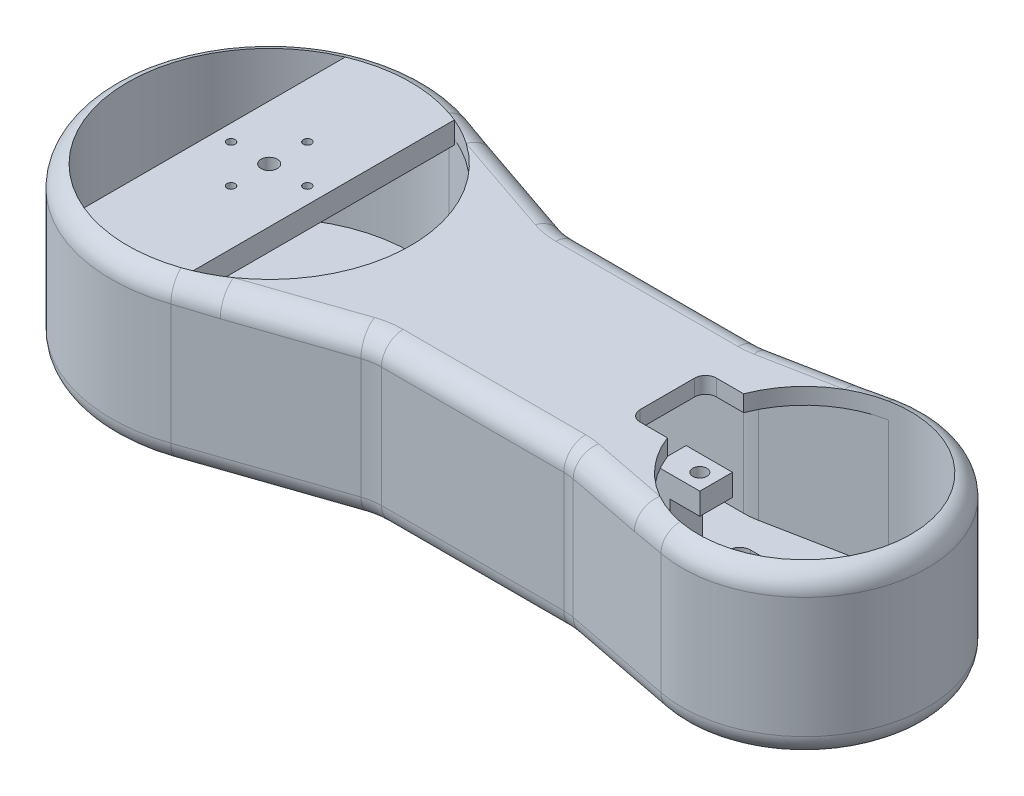
from build123d import *

# Parameters (mm, degrees)
BOSS_EXTRUDE1_DEPTH = 30
CUT_EXTRUDE3_START  = -3
CUT_EXTRUDE3_DEPTH  = 24
SKETCH6_R           = 25.98
SKETCH6_R_2         = 19.5
CUT_EXTRUDE4_DEPTH  = 9
FILLET1_R           = 4
SKETCH7_R           = 0.75
SKETCH7_R_2         = 1.5
BOSS_EXTRUDE2_DEPTH = 4
SKETCH8_R           = 5
CUT_EXTRUDE5_DEPTH  = 4
BOSS_EXTRUDE3_DEPTH = 4
SKETCH11_W          = 5.5
SKETCH11_H          = 6
SKETCH11_R          = 1.3
BOSS_EXTRUDE4_DEPTH = 4
SKETCH13_W          = 3
SKETCH13_H          = 6
BOSS_EXTRUDE5_DEPTH = 17.5
CUT_EXTRUDE6_DEPTH  = 4
CUT_EXTRUDE10_DEPTH = 4


with BuildPart() as part:
    # Sketch1 → Boss-Extrude1 (new body)
    with BuildSketch(Plane(origin=(0, 0, 0), x_dir=(1, 0, 0), z_dir=(0, 1, 0))):
        with BuildLine():
            Line((9.371736046, 27.4228183), (35.371736046, 18.537329779))
            ThreePointArc((35.371736046, 18.537329779), (36.966499389, 18.135247033), (38.605599416, 18))
            Line((38.605599416, 18), (72.067981377, 18))
            ThreePointArc((72.067981377, 18), (73.029258276, 18.046309894), (73.981631849, 18.184810655))
            Line((73.981631849, 18.184810655), (93.981631849, 22.084176026))
            ThreePointArc((93.981631849, 22.084176026), (120.78734541, 0), (93.981631849, -22.084176026))
            Line((93.981631849, -22.084176026), (73.981631849, -18.184810655))
            ThreePointArc((73.981631849, -18.184810655), (73.029258276, -18.046309894), (72.067981377, -18))
            Line((72.067981377, -18), (38.605599416, -18))
            ThreePointArc((38.605599416, -18), (36.966499389, -18.135247033), (35.371736046, -18.537329779))
            Line((35.371736046, -18.537329779), (9.371736046, -27.4228183))
            ThreePointArc((9.371736046, -27.4228183), (-28.98, 0), (9.371736046, 27.4228183))
        make_face()
    extrude(amount=BOSS_EXTRUDE1_DEPTH)

    # Sketch5 → Cut-Extrude3 (cut)
    with BuildSketch(Plane(origin=(0, 30, 0), x_dir=(1, 0, 0), z_dir=(0, 1, 0)).offset(CUT_EXTRUDE3_START)):
        with BuildLine():
            Line((8.401577035, -24.584017233), (34.401577035, -15.698528713))
            ThreePointArc((34.401577035, -15.698528713), (36.474769381, -15.175821143), (38.605599416, -15))
            Line((38.605599416, -15), (72.067981377, -15))
            ThreePointArc((72.067981377, -15), (73.317641346, -15.060202862), (74.55572699, -15.240253852))
            Line((74.55572699, -15.240253852), (94.55572699, -19.139619222))
            ThreePointArc((94.55572699, -19.139619222), (117.78734541, 0), (94.55572699, 19.139619222))
            Line((94.55572699, 19.139619222), (74.55572699, 15.240253852))
            ThreePointArc((74.55572699, 15.240253852), (73.317641346, 15.060202862), (72.067981377, 15))
            Line((72.067981377, 15), (38.605599416, 15))
            ThreePointArc((38.605599416, 15), (36.474769381, 15.175821143), (34.401577035, 15.698528713))
            Line((34.401577035, 15.698528713), (8.401577035, 24.584017233))
            ThreePointArc((8.401577035, 24.584017233), (-25.98, 0), (8.401577035, -24.584017233))
        make_face()
    extrude(amount=-CUT_EXTRUDE3_DEPTH, mode=Mode.SUBTRACT)

    # Sketch6 → Cut-Extrude4 (cut)
    with BuildSketch(Plane(origin=(0, 30, 0), x_dir=(1, 0, 0), z_dir=(0, 1, 0))):
        Circle(SKETCH6_R)
        with Locations((98.28734541, 0)):
            Circle(SKETCH6_R_2)
    extrude(amount=-CUT_EXTRUDE4_DEPTH, mode=Mode.SUBTRACT)

    # Fillet1
    fillet1_edges = [part.edges().sort_by_distance(p)[0] for p in [
        (73.029258276, 0, -18.046309894),
        (83.981631849, 0, -20.13449334),
        (120.78734541, 0, 0),
        (83.981631849, 0, 20.13449334),
        (73.029258276, 0, 18.046309894),
        (55.336790396, 0, 18),
        (36.966499389, 0, 18.135247033),
        (22.371736046, 0, 22.980074039),
        (-28.98, 0, 0),
        (22.371736046, 0, -22.980074039),
        (36.966499389, 0, -18.135247033),
        (36.966499389, 30, -18.135247033),
        (55.336790396, 30, -18),
        (73.029258276, 30, -18.046309894),
        (83.981631849, 30, -20.13449334),
        (83.981631849, 30, 20.13449334),
        (73.029258276, 30, 18.046309894),
        (55.336790396, 30, 18),
        (36.966499389, 30, 18.135247033),
        (22.371736046, 30, 22.980074039),
        (55.336790396, 0, -18),
        (22.371736046, 30, -22.980074039),
    ]]
    fillet(fillet1_edges, radius=FILLET1_R)

    # Sketch7 → Boss-Extrude2 (add)
    with BuildSketch(Plane(origin=(0, 30, 0), x_dir=(1, 0, 0), z_dir=(0, 1, 0))):
        with BuildLine():
            Line((10, -3.201562119), (10, 3.201562119))
            ThreePointArc((10, 3.201562119), (0, 10.5), (-10, 3.201562119))
            Line((-10, 3.201562119), (-10, -3.201562119))
            ThreePointArc((-10, -3.201562119), (0, -10.5), (10, -3.201562119))
        make_face()
        with Locations((0, -7)):
            Circle(SKETCH7_R, mode=Mode.SUBTRACT)
        with Locations((-7, 0)):
            Circle(SKETCH7_R, mode=Mode.SUBTRACT)
        Circle(SKETCH7_R_2, mode=Mode.SUBTRACT)
        with Locations((0, 7)):
            Circle(SKETCH7_R, mode=Mode.SUBTRACT)
        with Locations((7, 0)):
            Circle(SKETCH7_R, mode=Mode.SUBTRACT)
        with BuildLine():
            Line((10, 3.201562119), (10, 23.978331885))
            ThreePointArc((10, 23.978331885), (0, 25.98), (-10, 23.978331885))
            Line((-10, 23.978331885), (-10, 3.201562119))
            ThreePointArc((-10, 3.201562119), (0, 10.5), (10, 3.201562119))
        make_face()
        with BuildLine():
            Line((10, -23.978331885), (10, -3.201562119))
            ThreePointArc((10, -3.201562119), (0, -10.5), (-10, -3.201562119))
            Line((-10, -3.201562119), (-10, -23.978331885))
            ThreePointArc((-10, -23.978331885), (0, -25.98), (10, -23.978331885))
        make_face()
    extrude(amount=-BOSS_EXTRUDE2_DEPTH)

    # Sketch8 → Cut-Extrude5 (cut)
    with BuildSketch(Plane.XZ):
        Circle(SKETCH8_R)
    extrude(amount=-CUT_EXTRUDE5_DEPTH, mode=Mode.SUBTRACT)

    # Sketch10 → Boss-Extrude3 (add)
    with BuildSketch(Plane(origin=(0, 16.5, 0), x_dir=(1, 0, 0), z_dir=(0, 1, 0))):
        with BuildLine():
            Line((103.73734541, 1), (103.73734541, 0))
            Line((103.73734541, 0), (103.73734541, -1))
            ThreePointArc((103.73734541, -1), (104.323131847, -2.414213562), (105.73734541, -3))
            Line((105.73734541, -3), (117.555194278, -3))
            ThreePointArc((117.555194278, -3), (117.729221, -1.504484476), (117.78734541, 0))
            ThreePointArc((117.78734541, 0), (117.729221, 1.504484476), (117.555194278, 3))
            Line((117.555194278, 3), (105.73734541, 3))
            ThreePointArc((105.73734541, 3), (104.323131847, 2.414213562), (103.73734541, 1))
        make_face()
        with BuildLine():
            ThreePointArc((108.03734541, 0), (106.73734541, -1.3), (105.43734541, 0))
            ThreePointArc((105.43734541, 0), (106.73734541, 1.3), (108.03734541, 0))
        make_face(mode=Mode.SUBTRACT)
    extrude(amount=-BOSS_EXTRUDE3_DEPTH)



with BuildPart() as body_2:
    # Sketch11 → Boss-Extrude4 (new body)
    with BuildSketch(Plane(origin=(0, 16.5, 0), x_dir=(1, 0, 0), z_dir=(0, 1, 0))):
        with Locations((79.28734541, 0)):
            Rectangle(SKETCH11_W, SKETCH11_H)
        with Locations((79.03734541, 0)):
            Circle(SKETCH11_R, mode=Mode.SUBTRACT)
    extrude(amount=BOSS_EXTRUDE4_DEPTH)


with BuildPart() as part_1:
    add(part.part)

    add(body_2.part)  # Boss-Extrude5 merges body 2
    # Sketch13 → Boss-Extrude5 (add)
    with BuildSketch(Plane(origin=(0, 20.5, 0), x_dir=(1, 0, 0), z_dir=(0, 1, 0))):
        with Locations((75.03734541, 0)):
            Rectangle(SKETCH13_W, SKETCH13_H)
    extrude(amount=-BOSS_EXTRUDE5_DEPTH)

    # Sketch14 → Cut-Extrude6 (cut)
    with BuildSketch(Plane(origin=(0, 30, 0), x_dir=(1, 0, 0), z_dir=(0, 1, 0))):
        with BuildLine():
            Line((80.087070687, 7), (75.087070687, 7))
            ThreePointArc((75.087070687, 7), (73.672857124, 6.414213562), (73.087070687, 5))
            Line((73.087070687, 5), (73.087070687, -5))
            ThreePointArc((73.087070687, -5), (73.672857124, -6.414213562), (75.087070687, -7))
            Line((75.087070687, -7), (80.087070687, -7))
            ThreePointArc((80.087070687, -7), (79.242622942, -4.189098484), (78.829618137, -1.283296295))
            ThreePointArc((78.829618137, -1.283296295), (77.73734541, 0), (78.829618137, 1.283296295))
            ThreePointArc((78.829618137, 1.283296295), (79.242622942, 4.189098484), (80.087070687, 7))
        make_face()
        with BuildLine():
            ThreePointArc((80.33734541, 0), (79.879946901, 0.989960973), (78.829618137, 1.283296295))
            ThreePointArc((78.829618137, 1.283296295), (78.78734541, 0), (78.829618137, -1.283296295))
            ThreePointArc((78.829618137, -1.283296295), (79.879946901, -0.989960973), (80.33734541, 0))
        make_face()
        with BuildLine():
            ThreePointArc((78.829618137, -1.283296295), (78.78734541, 0), (78.829618137, 1.283296295))
            ThreePointArc((78.829618137, 1.283296295), (77.73734541, 0), (78.829618137, -1.283296295))
        make_face()
    extrude(amount=-CUT_EXTRUDE6_DEPTH, mode=Mode.SUBTRACT)

    # Sketch15 → Cut-Extrude10 (cut)
    with BuildSketch(Plane.XZ):
        with BuildLine():
            ThreePointArc((76.53734541, 7.8), (77.123131847, 9.214213562), (78.53734541, 9.8))
            Line((78.53734541, 9.8), (107.628930167, 9.8))
            ThreePointArc((107.628930167, 9.8), (109.04314373, 9.214213562), (109.628930167, 7.8))
            Line((109.628930167, 7.8), (109.628930167, -7.8))
            ThreePointArc((109.628930167, -7.8), (109.04314373, -9.214213562), (107.628930167, -9.8))
            Line((107.628930167, -9.8), (78.53734541, -9.8))
            ThreePointArc((78.53734541, -9.8), (77.123131847, -9.214213562), (76.53734541, -7.8))
            Line((76.53734541, -7.8), (76.53734541, 7.8))
        make_face()
    extrude(amount=-CUT_EXTRUDE10_DEPTH, mode=Mode.SUBTRACT)


solid = part_1.part
